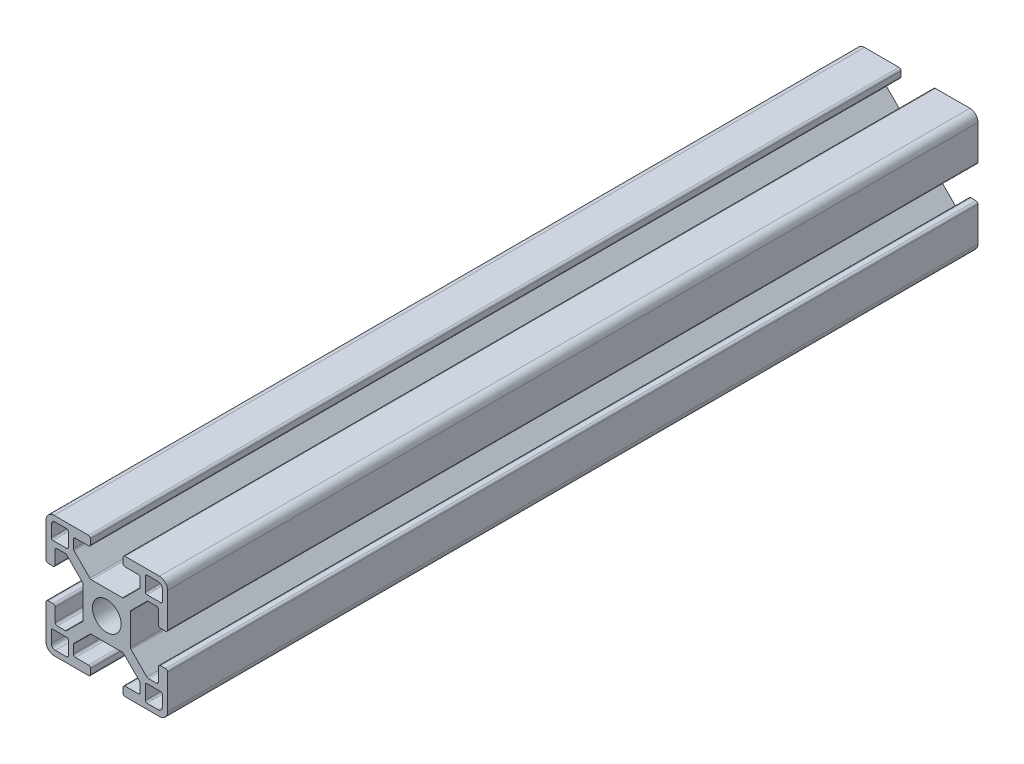
from build123d import *

# Parameters (mm, degrees)
SKETCH1_R           = 3.52998588
BOSS_EXTRUDE1_DEPTH = 100


with BuildPart() as part:
    # Sketch1 → Boss-Extrude1 (new body, symmetric)
    with BuildSketch(Plane.XY):
        with BuildLine():
            Line((14.49994, -4), (13.24247465, -4))
            ThreePointArc((13.24247465, -4), (12.88892126, -4.146446609), (12.74247465, -4.5))
            Line((12.74247465, -4.5), (12.74247465, -7.732519321))
            ThreePointArc((12.74247465, -7.732519321), (12.602449697, -8.097296796), (12.242781236, -8.249967))
            Line((12.242781236, -8.249967), (10.260188032, -8.249967))
            ThreePointArc((10.260188032, -8.249967), (10.068847082, -8.211906919), (9.906636056, -8.103520976))
            Line((9.906636056, -8.103520976), (5.981117769, -4.178002689))
            ThreePointArc((5.981117769, -4.178002689), (5.872731827, -4.015791664), (5.834671745, -3.824450713))
            Line((5.834671745, -3.824450713), (5.834671745, -1.01249595))
            Line((5.834671745, -1.01249595), (5.834671745, 0.88749645))
            Line((5.834671745, 0.88749645), (5.834671745, 3.824450713))
            ThreePointArc((5.834671745, 3.824450713), (5.872731827, 4.015791664), (5.981117769, 4.178002689))
            Line((5.981117769, 4.178002689), (9.906636056, 8.103520976))
            ThreePointArc((9.906636056, 8.103520976), (10.068847082, 8.211906919), (10.260188032, 8.249967))
            Line((10.260188032, 8.249967), (12.242781236, 8.249967))
            ThreePointArc((12.242781236, 8.249967), (12.602449697, 8.097296796), (12.74247465, 7.732519321))
            Line((12.74247465, 7.732519321), (12.74247465, 4.5))
            ThreePointArc((12.74247465, 4.5), (12.88892126, 4.146446609), (13.24247465, 4))
            Line((13.24247465, 4), (14.49994, 4))
            ThreePointArc((14.49994, 4), (14.853493391, 4.146446609), (14.99994, 4.5))
            Line((14.99994, 4.5), (14.99994, 12.999948))
            ThreePointArc((14.99994, 12.999948), (14.414155906, 14.414155906), (12.999948, 14.99994))
            Line((12.999948, 14.99994), (4.5, 14.99994))
            ThreePointArc((4.5, 14.99994), (4.146446609, 14.853493391), (4, 14.49994))
            Line((4, 14.49994), (4, 13.24247465))
            ThreePointArc((4, 13.24247465), (4.146446609, 12.88892126), (4.5, 12.74247465))
            Line((4.5, 12.74247465), (7.732519321, 12.74247465))
            ThreePointArc((7.732519321, 12.74247465), (8.097296796, 12.602449697), (8.249967, 12.242781236))
            Line((8.249967, 12.242781236), (8.249967, 10.260188032))
            ThreePointArc((8.249967, 10.260188032), (8.211906919, 10.068847082), (8.103520976, 9.906636056))
            Line((8.103520976, 9.906636056), (4.178002689, 5.981117769))
            ThreePointArc((4.178002689, 5.981117769), (4.015791664, 5.872731827), (3.824450713, 5.834671745))
            Line((3.824450713, 5.834671745), (0.9499962, 5.834671745))
            Line((0.9499962, 5.834671745), (-0.9499962, 5.834671745))
            Line((-0.9499962, 5.834671745), (-3.824450713, 5.834671745))
            ThreePointArc((-3.824450713, 5.834671745), (-4.015791664, 5.872731827), (-4.178002689, 5.981117769))
            Line((-4.178002689, 5.981117769), (-8.103520976, 9.906636056))
            ThreePointArc((-8.103520976, 9.906636056), (-8.211906919, 10.068847082), (-8.249967, 10.260188032))
            Line((-8.249967, 10.260188032), (-8.249967, 12.242781236))
            ThreePointArc((-8.249967, 12.242781236), (-8.097296796, 12.602449697), (-7.732519321, 12.74247465))
            Line((-7.732519321, 12.74247465), (-4.5, 12.74247465))
            ThreePointArc((-4.5, 12.74247465), (-4.146446609, 12.88892126), (-4, 13.24247465))
            Line((-4, 13.24247465), (-4, 14.49994))
            ThreePointArc((-4, 14.49994), (-4.146446609, 14.853493391), (-4.5, 14.99994))
            Line((-4.5, 14.99994), (-12.999948, 14.99994))
            ThreePointArc((-12.999948, 14.99994), (-14.414155906, 14.414155906), (-14.99994, 12.999948))
            Line((-14.99994, 12.999948), (-14.99994, 4.5))
            ThreePointArc((-14.99994, 4.5), (-14.853493391, 4.146446609), (-14.49994, 4))
            Line((-14.49994, 4), (-13.24247465, 4))
            ThreePointArc((-13.24247465, 4), (-12.88892126, 4.146446609), (-12.74247465, 4.5))
            Line((-12.74247465, 4.5), (-12.74247465, 7.732519321))
            ThreePointArc((-12.74247465, 7.732519321), (-12.602449697, 8.097296796), (-12.242781236, 8.249967))
            Line((-12.242781236, 8.249967), (-10.260188032, 8.249967))
            ThreePointArc((-10.260188032, 8.249967), (-10.068847082, 8.211906919), (-9.906636056, 8.103520976))
            Line((-9.906636056, 8.103520976), (-5.981117769, 4.178002689))
            ThreePointArc((-5.981117769, 4.178002689), (-5.872731827, 4.015791664), (-5.834671745, 3.824450713))
            Line((-5.834671745, 3.824450713), (-5.834671745, 0.88749645))
            Line((-5.834671745, 0.88749645), (-5.834671745, -1.01249595))
            Line((-5.834671745, -1.01249595), (-5.834671745, -3.824450713))
            ThreePointArc((-5.834671745, -3.824450713), (-5.872731827, -4.015791664), (-5.981117769, -4.178002689))
            Line((-5.981117769, -4.178002689), (-9.906636056, -8.103520976))
            ThreePointArc((-9.906636056, -8.103520976), (-10.068847082, -8.211906919), (-10.260188032, -8.249967))
            Line((-10.260188032, -8.249967), (-12.242781236, -8.249967))
            ThreePointArc((-12.242781236, -8.249967), (-12.602449697, -8.097296796), (-12.74247465, -7.732519321))
            Line((-12.74247465, -7.732519321), (-12.74247465, -4.5))
            ThreePointArc((-12.74247465, -4.5), (-12.88892126, -4.146446609), (-13.24247465, -4))
            Line((-13.24247465, -4), (-14.49994, -4))
            ThreePointArc((-14.49994, -4), (-14.853493391, -4.146446609), (-14.99994, -4.5))
            Line((-14.99994, -4.5), (-14.99994, -12.999948))
            ThreePointArc((-14.99994, -12.999948), (-14.414155906, -14.414155906), (-12.999948, -14.99994))
            Line((-12.999948, -14.99994), (-4.5, -14.99994))
            ThreePointArc((-4.5, -14.99994), (-4.146446609, -14.853493391), (-4, -14.49994))
            Line((-4, -14.49994), (-4, -13.24247465))
            ThreePointArc((-4, -13.24247465), (-4.146446609, -12.88892126), (-4.5, -12.74247465))
            Line((-4.5, -12.74247465), (-7.732519321, -12.74247465))
            ThreePointArc((-7.732519321, -12.74247465), (-8.097296796, -12.602449697), (-8.249967, -12.242781236))
            Line((-8.249967, -12.242781236), (-8.249967, -10.260188032))
            ThreePointArc((-8.249967, -10.260188032), (-8.211906919, -10.068847082), (-8.103520976, -9.906636056))
            Line((-8.103520976, -9.906636056), (-4.178002689, -5.981117769))
            ThreePointArc((-4.178002689, -5.981117769), (-4.015791664, -5.872731827), (-3.824450713, -5.834671745))
            Line((-3.824450713, -5.834671745), (-0.9499962, -5.834671745))
            Line((-0.9499962, -5.834671745), (0.9499962, -5.834671745))
            Line((0.9499962, -5.834671745), (3.824450713, -5.834671745))
            ThreePointArc((3.824450713, -5.834671745), (4.015791664, -5.872731827), (4.178002689, -5.981117769))
            Line((4.178002689, -5.981117769), (8.103520976, -9.906636056))
            ThreePointArc((8.103520976, -9.906636056), (8.211906919, -10.068847082), (8.249967, -10.260188032))
            Line((8.249967, -10.260188032), (8.249967, -12.242781236))
            ThreePointArc((8.249967, -12.242781236), (8.097296796, -12.602449697), (7.732519321, -12.74247465))
            Line((7.732519321, -12.74247465), (4.5, -12.74247465))
            ThreePointArc((4.5, -12.74247465), (4.146446609, -12.88892126), (4, -13.24247465))
            Line((4, -13.24247465), (4, -14.49994))
            ThreePointArc((4, -14.49994), (4.146446609, -14.853493391), (4.5, -14.99994))
            Line((4.5, -14.99994), (12.999948, -14.99994))
            ThreePointArc((12.999948, -14.99994), (14.414155906, -14.414155906), (14.99994, -12.999948))
            Line((14.99994, -12.999948), (14.99994, -4.5))
            ThreePointArc((14.99994, -4.5), (14.853493391, -4.146446609), (14.49994, -4))
        make_face()
        Circle(SKETCH1_R, mode=Mode.SUBTRACT)
        with BuildLine():
            Line((-12.6999492, -13.6999452), (-9.880960476, -13.6999452))
            ThreePointArc((-9.880960476, -13.6999452), (-9.61155387, -13.58835333), (-9.499962, -13.318946724))
            Line((-9.499962, -13.318946724), (-9.499962, -9.87996048))
            ThreePointArc((-9.499962, -9.87996048), (-9.611260978, -9.611260978), (-9.87996048, -9.499962))
            Line((-9.87996048, -9.499962), (-13.318946724, -9.499962))
            ThreePointArc((-13.318946724, -9.499962), (-13.58835333, -9.61155387), (-13.6999452, -9.880960476))
            Line((-13.6999452, -9.880960476), (-13.6999452, -12.6999492))
            ThreePointArc((-13.6999452, -12.6999492), (-13.407053153, -13.407053153), (-12.6999492, -13.6999452))
        make_face(mode=Mode.SUBTRACT)
        with BuildLine():
            Line((13.6999452, -12.6999492), (13.6999452, -9.880960476))
            ThreePointArc((13.6999452, -9.880960476), (13.58835333, -9.61155387), (13.318946724, -9.499962))
            Line((13.318946724, -9.499962), (9.87996048, -9.499962))
            ThreePointArc((9.87996048, -9.499962), (9.611260978, -9.611260978), (9.499962, -9.87996048))
            Line((9.499962, -9.87996048), (9.499962, -13.318946724))
            ThreePointArc((9.499962, -13.318946724), (9.61155387, -13.58835333), (9.880960476, -13.6999452))
            Line((9.880960476, -13.6999452), (12.6999492, -13.6999452))
            ThreePointArc((12.6999492, -13.6999452), (13.407053153, -13.407053153), (13.6999452, -12.6999492))
        make_face(mode=Mode.SUBTRACT)
        with BuildLine():
            Line((9.87996048, 9.499962), (13.318946724, 9.499962))
            ThreePointArc((13.318946724, 9.499962), (13.58835333, 9.61155387), (13.6999452, 9.880960476))
            Line((13.6999452, 9.880960476), (13.6999452, 12.6999492))
            ThreePointArc((13.6999452, 12.6999492), (13.407053153, 13.407053153), (12.6999492, 13.6999452))
            Line((12.6999492, 13.6999452), (9.880960476, 13.6999452))
            ThreePointArc((9.880960476, 13.6999452), (9.61155387, 13.58835333), (9.499962, 13.318946724))
            Line((9.499962, 13.318946724), (9.499962, 9.87996048))
            ThreePointArc((9.499962, 9.87996048), (9.611260978, 9.611260978), (9.87996048, 9.499962))
        make_face(mode=Mode.SUBTRACT)
        with BuildLine():
            Line((-13.6999452, 12.6999492), (-13.6999452, 9.880960476))
            ThreePointArc((-13.6999452, 9.880960476), (-13.58835333, 9.61155387), (-13.318946724, 9.499962))
            Line((-13.318946724, 9.499962), (-9.87996048, 9.499962))
            ThreePointArc((-9.87996048, 9.499962), (-9.611260978, 9.611260978), (-9.499962, 9.87996048))
            Line((-9.499962, 9.87996048), (-9.499962, 13.318946724))
            ThreePointArc((-9.499962, 13.318946724), (-9.61155387, 13.58835333), (-9.880960476, 13.6999452))
            Line((-9.880960476, 13.6999452), (-12.6999492, 13.6999452))
            ThreePointArc((-12.6999492, 13.6999452), (-13.407053153, 13.407053153), (-13.6999452, 12.6999492))
        make_face(mode=Mode.SUBTRACT)
    extrude(amount=BOSS_EXTRUDE1_DEPTH, both=True)


solid = part.part
